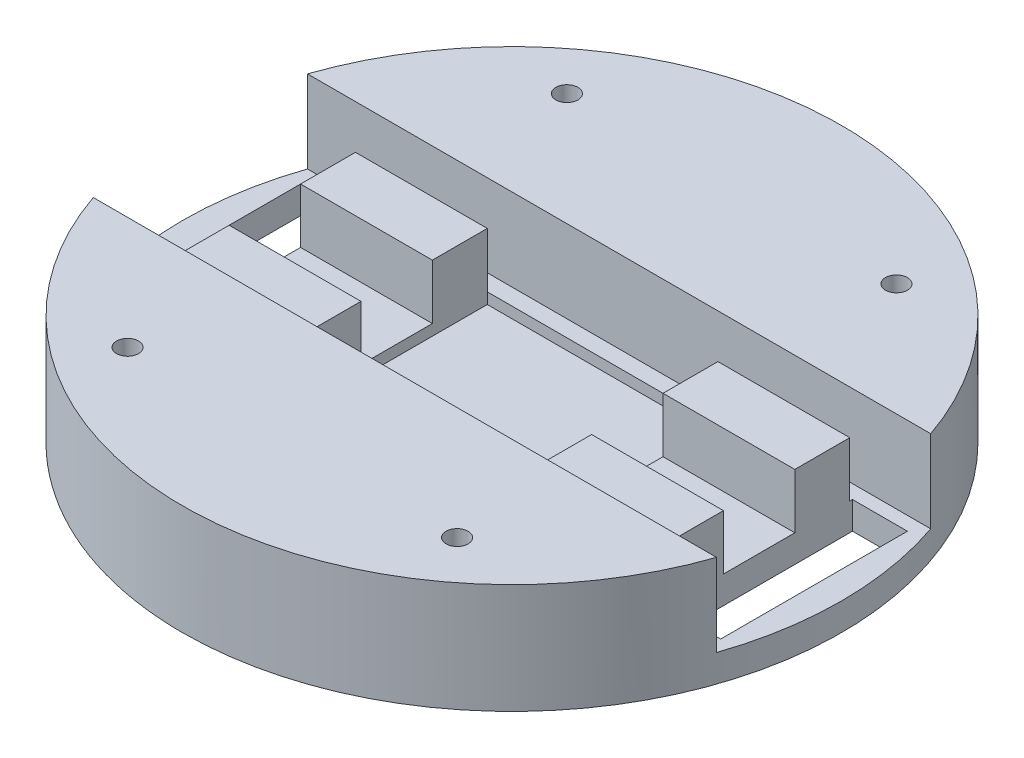
from build123d import *

# Parameters (mm, degrees)
SKETCH1_R               = 60
BOSS_EXTRUDE1_DEPTH     = 5
SKETCH2_W               = 10
SKETCH2_H               = 34
CUT_EXTRUDE1_DEPTH      = 1
CUT_EXTRUDE1_DEPTH_BACK = 6
SKETCH3_W               = 24
SKETCH3_H               = 10
BOSS_EXTRUDE2_DEPTH     = 10
SKETCH4_W               = 42
SKETCH4_H               = 33
CUT_EXTRUDE2_DEPTH      = 2
BOSS_EXTRUDE3_DEPTH     = 15
SKETCH6_R               = 2
CUT_EXTRUDE3_DEPTH      = 10


with BuildPart() as part:
    # Sketch1 → Boss-Extrude1 (new body)
    with BuildSketch(Plane(origin=(0, 0, 0), x_dir=(1, 0, 0), z_dir=(0, 1, 0))):
        Circle(SKETCH1_R)
    extrude(amount=BOSS_EXTRUDE1_DEPTH)

    # Sketch2 → Cut-Extrude1 (cut, two sides)
    with BuildSketch(Plane(origin=(0, 5, 0), x_dir=(1, 0, 0), z_dir=(0, 1, 0))) as cut_extrude1_sk:
        with Locations((-50, 0)):
            Rectangle(SKETCH2_W, SKETCH2_H)
        with Locations((50, 0)):
            Rectangle(SKETCH2_W, SKETCH2_H)
    extrude(amount=CUT_EXTRUDE1_DEPTH, mode=Mode.SUBTRACT)
    extrude(cut_extrude1_sk.sketch, amount=-CUT_EXTRUDE1_DEPTH_BACK, mode=Mode.SUBTRACT)

    # Sketch3 → Boss-Extrude2 (add)
    with BuildSketch(Plane(origin=(0, 5, 0), x_dir=(1, 0, 0), z_dir=(0, 1, 0))):
        with Locations((-33, -11.5)):
            Rectangle(SKETCH3_W, SKETCH3_H)
        with Locations((-33, 11.5)):
            Rectangle(SKETCH3_W, SKETCH3_H)
        with Locations((33, -11.5)):
            Rectangle(SKETCH3_W, SKETCH3_H)
        with Locations((33, 11.5)):
            Rectangle(SKETCH3_W, SKETCH3_H)
    extrude(amount=BOSS_EXTRUDE2_DEPTH)

    # Sketch4 → Cut-Extrude2 (cut)
    with BuildSketch(Plane(origin=(0, 5, 0), x_dir=(1, 0, 0), z_dir=(0, 1, 0))):
        Rectangle(SKETCH4_W, SKETCH4_H)
    extrude(amount=-CUT_EXTRUDE2_DEPTH, mode=Mode.SUBTRACT)

    # Sketch5 → Boss-Extrude3 (add)
    with BuildSketch(Plane(origin=(0, 5, 0), x_dir=(1, 0, 0), z_dir=(0, 1, 0))):
        with BuildLine():
            Line((-56.742840958, 19.5), (56.742840958, 19.5))
            ThreePointArc((56.742840958, 19.5), (0, 60), (-56.742840958, 19.5))
        make_face()
        with BuildLine():
            Line((-56.742840958, -19.5), (56.742840958, -19.5))
            ThreePointArc((56.742840958, -19.5), (0, -60), (-56.742840958, -19.5))
        make_face()
    extrude(amount=BOSS_EXTRUDE3_DEPTH)

    # Sketch6 → Cut-Extrude3 (cut)
    with BuildSketch(Plane(origin=(0, 20, 0), x_dir=(1, 0, 0), z_dir=(0, 1, 0))):
        with Locations((30, -40)):
            Circle(SKETCH6_R)
        with Locations((-30, -40)):
            Circle(SKETCH6_R)
        with Locations((30, 40)):
            Circle(SKETCH6_R)
        with Locations((-30, 40)):
            Circle(SKETCH6_R)
    extrude(amount=-CUT_EXTRUDE3_DEPTH, mode=Mode.SUBTRACT)

    # Sketch7 → Revolve1 (revolve)
    with BuildSketch(Plane(origin=(0, 0, 0), x_dir=(0, 0, -1), z_dir=(1, 0, 0))):
        with BuildLine():
            Line((-39.75, 0), (-39.75, -6.5))
            ThreePointArc((-39.75, -6.5), (-29.119335131, -4.825340555), (-19.5, 0))
            Line((-19.5, 0), (-39.75, 0))
        make_face()
    revolve(axis=Axis((0, 0, 39.75), (0, -1, 0)))


solid = part.part
